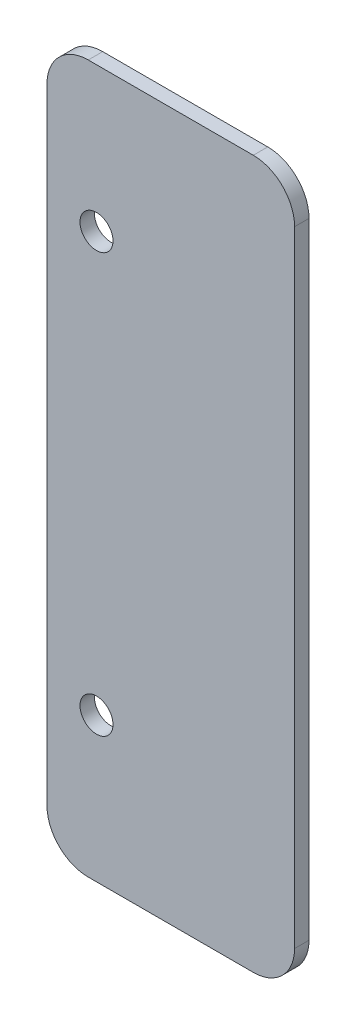
from build123d import *

# Parameters (mm, degrees)
SKETCH_1_W          = 60
SKETCH_1_H          = 171.5
EXTRUDE_1_DEPTH     = 3.5
FILLET_1_R          = 10
CUT_EXTRUDE_1_REACH = 5.5
SKETCH_2_R          = 4


with BuildPart() as part:
    # 草图1 → 凸台-拉伸1 (new body)
    with BuildSketch(Plane.XY):
        with Locations((2332, -8)):
            Rectangle(SKETCH_1_W, SKETCH_1_H)
    extrude(amount=EXTRUDE_1_DEPTH)

    # 圆角1
    fillet_1_edges = [part.edges().sort_by_distance(p)[0] for p in [
        (2302, -93.75, 1.75),
        (2302, 77.75, 1.75),
        (2362, 77.75, 1.75),
        (2362, -93.75, 1.75),
    ]]
    fillet(fillet_1_edges, radius=FILLET_1_R)

    # 草图2 → 切除-拉伸1 (cut, up to next)
    with BuildSketch(Plane.XY.offset(3.5), mode=Mode.PRIVATE) as cut_extrude_1_sk1:
        with Locations((2314, 42.75)):
            Circle(SKETCH_2_R)
    cut_extrude_1_tool1 = extrude(cut_extrude_1_sk1.sketch, amount=-CUT_EXTRUDE_1_REACH, mode=Mode.PRIVATE) & part.part
    add(cut_extrude_1_tool1.solids().sort_by_distance((2314, 42.75, 3.5))[0], mode=Mode.SUBTRACT)
    # 草图2 → 切除-拉伸1 (cut, up to next)
    with BuildSketch(Plane.XY.offset(3.5), mode=Mode.PRIVATE) as cut_extrude_1_sk2:
        with Locations((2314, -58.75)):
            Circle(SKETCH_2_R)
    cut_extrude_1_tool2 = extrude(cut_extrude_1_sk2.sketch, amount=-CUT_EXTRUDE_1_REACH, mode=Mode.PRIVATE) & part.part
    add(cut_extrude_1_tool2.solids().sort_by_distance((2314, -58.75, 3.5))[0], mode=Mode.SUBTRACT)


solid = part.part
